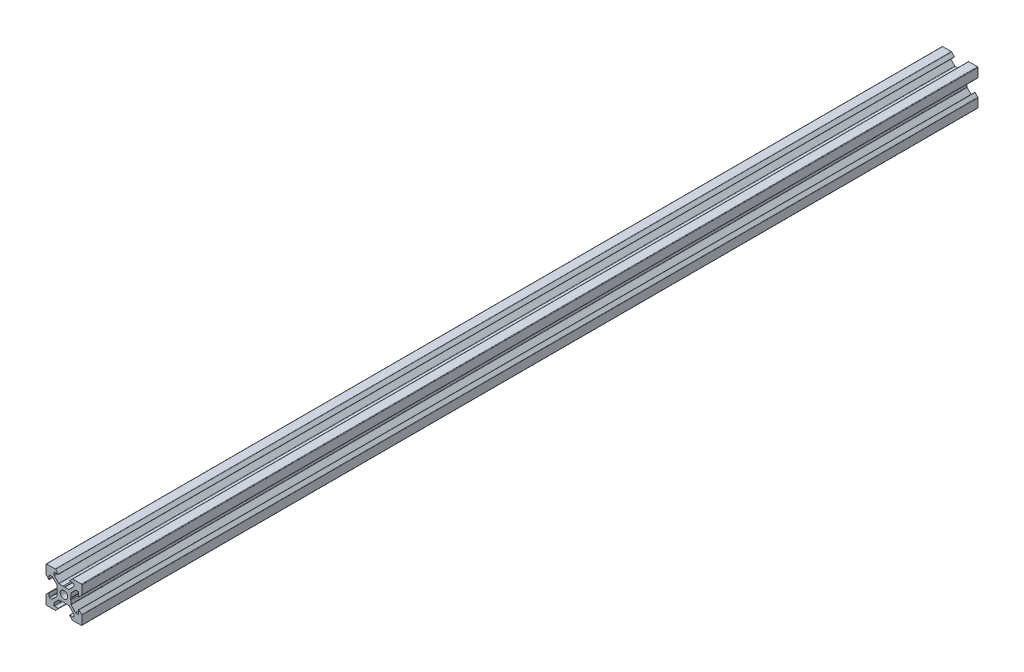
from build123d import *

# Parameters (mm, degrees)
BOSS_EXTRU_1_DEPTH = 500


with BuildPart() as part:
    # Esquisse1 → Boss.-Extru.1 (new body)
    with BuildSketch(Plane.XY):
        with BuildLine():
            Line((18.774857412, -2.895228684), (18.774857412, -4.894568513))
            ThreePointArc((18.774857412, -4.894568513), (18.686989447, -5.106700547), (18.474857412, -5.194568513))
            Line((18.474857412, -5.194568513), (17.259121481, -5.194568513))
            ThreePointArc((17.259121481, -5.194568513), (17.144316451, -5.171732372), (17.046989447, -5.106700547))
            Line((17.046989447, -5.106700547), (14.56338555, -2.62309665))
            ThreePointArc((14.56338555, -2.62309665), (14.498353724, -2.525769645), (14.475517584, -2.410964616))
            Line((14.475517584, -2.410964616), (14.475517584, -0.214843927))
            Line((14.475517584, -0.214843927), (14.175517584, 0.304771316))
            Line((14.175517584, 0.304771316), (14.475517584, 0.824386558))
            Line((14.475517584, 0.824386558), (14.475517584, 3.020507247))
            ThreePointArc((14.475517584, 3.020507247), (14.498353724, 3.135312277), (14.56338555, 3.232639281))
            Line((14.56338555, 3.232639281), (17.046989447, 5.716243178))
            ThreePointArc((17.046989447, 5.716243178), (17.144316451, 5.781275004), (17.259121481, 5.804111144))
            Line((17.259121481, 5.804111144), (18.474857412, 5.804111144))
            ThreePointArc((18.474857412, 5.804111144), (18.686989447, 5.716243178), (18.774857412, 5.504111144))
            Line((18.774857412, 5.504111144), (18.774857412, 3.504771316))
            ThreePointArc((18.774857412, 3.504771316), (18.836589069, 3.412383362), (18.94556809, 3.434060638))
            Line((18.94556809, 3.434060638), (20.486989447, 4.975481994))
            ThreePointArc((20.486989447, 4.975481994), (20.552021272, 5.072808998), (20.574857412, 5.187614028))
            Line((20.574857412, 5.187614028), (20.574857412, 10.004771316))
            ThreePointArc((20.574857412, 10.004771316), (20.486989447, 10.21690335), (20.274857412, 10.304771316))
            Line((20.274857412, 10.304771316), (15.457700125, 10.304771316))
            ThreePointArc((15.457700125, 10.304771316), (15.342895095, 10.281935175), (15.24556809, 10.21690335))
            Line((15.24556809, 10.21690335), (13.704146734, 8.675481994))
            ThreePointArc((13.704146734, 8.675481994), (13.682469459, 8.566502972), (13.774857412, 8.504771316))
            Line((13.774857412, 8.504771316), (15.77419724, 8.504771316))
            ThreePointArc((15.77419724, 8.504771316), (15.986329275, 8.41690335), (16.07419724, 8.204771316))
            Line((16.07419724, 8.204771316), (16.07419724, 6.989035384))
            ThreePointArc((16.07419724, 6.989035384), (16.0513611, 6.874230355), (15.986329275, 6.77690335))
            Line((15.986329275, 6.77690335), (13.502725378, 4.293299453))
            ThreePointArc((13.502725378, 4.293299453), (13.405398373, 4.228267628), (13.290593344, 4.205431487))
            Line((13.290593344, 4.205431487), (11.094472654, 4.205431487))
            Line((11.094472654, 4.205431487), (10.574857412, 3.905431487))
            Line((10.574857412, 3.905431487), (10.05524217, 4.205431487))
            Line((10.05524217, 4.205431487), (7.859121481, 4.205431487))
            ThreePointArc((7.859121481, 4.205431487), (7.744316451, 4.228267628), (7.646989447, 4.293299453))
            Line((7.646989447, 4.293299453), (5.16338555, 6.77690335))
            ThreePointArc((5.16338555, 6.77690335), (5.098353724, 6.874230355), (5.075517584, 6.989035384))
            Line((5.075517584, 6.989035384), (5.075517584, 8.204771316))
            ThreePointArc((5.075517584, 8.204771316), (5.16338555, 8.41690335), (5.375517584, 8.504771316))
            Line((5.375517584, 8.504771316), (7.374857412, 8.504771316))
            ThreePointArc((7.374857412, 8.504771316), (7.467245365, 8.566502972), (7.44556809, 8.675481994))
            Line((7.44556809, 8.675481994), (5.904146734, 10.21690335))
            ThreePointArc((5.904146734, 10.21690335), (5.806819729, 10.281935175), (5.6920147, 10.304771316))
            Line((5.6920147, 10.304771316), (0.874857412, 10.304771316))
            ThreePointArc((0.874857412, 10.304771316), (0.662725378, 10.21690335), (0.574857412, 10.004771316))
            Line((0.574857412, 10.004771316), (0.574857412, 5.187614028))
            ThreePointArc((0.574857412, 5.187614028), (0.597693552, 5.072808998), (0.662725378, 4.975481994))
            Line((0.662725378, 4.975481994), (2.204146734, 3.434060638))
            ThreePointArc((2.204146734, 3.434060638), (2.313125755, 3.412383362), (2.374857412, 3.504771316))
            Line((2.374857412, 3.504771316), (2.374857412, 5.504111144))
            ThreePointArc((2.374857412, 5.504111144), (2.462725378, 5.716243178), (2.674857412, 5.804111144))
            Line((2.674857412, 5.804111144), (3.890593344, 5.804111144))
            ThreePointArc((3.890593344, 5.804111144), (4.005398373, 5.781275004), (4.102725378, 5.716243178))
            Line((4.102725378, 5.716243178), (6.586329275, 3.232639281))
            ThreePointArc((6.586329275, 3.232639281), (6.6513611, 3.135312277), (6.67419724, 3.020507247))
            Line((6.67419724, 3.020507247), (6.67419724, 0.824386558))
            Line((6.67419724, 0.824386558), (6.97419724, 0.304771316))
            Line((6.97419724, 0.304771316), (6.67419724, -0.214843927))
            Line((6.67419724, -0.214843927), (6.67419724, -2.410964616))
            ThreePointArc((6.67419724, -2.410964616), (6.6513611, -2.525769645), (6.586329275, -2.62309665))
            Line((6.586329275, -2.62309665), (4.102725378, -5.106700547))
            ThreePointArc((4.102725378, -5.106700547), (4.005398373, -5.171732372), (3.890593344, -5.194568513))
            Line((3.890593344, -5.194568513), (2.674857412, -5.194568513))
            ThreePointArc((2.674857412, -5.194568513), (2.462725378, -5.106700547), (2.374857412, -4.894568513))
            Line((2.374857412, -4.894568513), (2.374857412, -2.895228684))
            ThreePointArc((2.374857412, -2.895228684), (2.313125755, -2.802840731), (2.204146734, -2.824518006))
            Line((2.204146734, -2.824518006), (0.662725378, -4.365939362))
            ThreePointArc((0.662725378, -4.365939362), (0.597693552, -4.463266367), (0.574857412, -4.578071397))
            Line((0.574857412, -4.578071397), (0.574857412, -9.395228684))
            ThreePointArc((0.574857412, -9.395228684), (0.662725378, -9.607360719), (0.874857412, -9.695228684))
            Line((0.874857412, -9.695228684), (5.6920147, -9.695228684))
            ThreePointArc((5.6920147, -9.695228684), (5.806819729, -9.672392544), (5.904146734, -9.607360719))
            Line((5.904146734, -9.607360719), (7.44556809, -8.065939362))
            ThreePointArc((7.44556809, -8.065939362), (7.467245365, -7.956960341), (7.374857412, -7.895228684))
            Line((7.374857412, -7.895228684), (5.375517584, -7.895228684))
            ThreePointArc((5.375517584, -7.895228684), (5.16338555, -7.807360719), (5.075517584, -7.595228684))
            Line((5.075517584, -7.595228684), (5.075517584, -6.379492753))
            ThreePointArc((5.075517584, -6.379492753), (5.098353724, -6.264687723), (5.16338555, -6.167360719))
            Line((5.16338555, -6.167360719), (7.646989447, -3.683756822))
            ThreePointArc((7.646989447, -3.683756822), (7.744316451, -3.618724996), (7.859121481, -3.595888856))
            Line((7.859121481, -3.595888856), (10.05524217, -3.595888856))
            Line((10.05524217, -3.595888856), (10.574857412, -3.295888856))
            Line((10.574857412, -3.295888856), (11.094472654, -3.595888856))
            Line((11.094472654, -3.595888856), (13.290593344, -3.595888856))
            ThreePointArc((13.290593344, -3.595888856), (13.405398373, -3.618724996), (13.502725378, -3.683756822))
            Line((13.502725378, -3.683756822), (15.986329275, -6.167360719))
            ThreePointArc((15.986329275, -6.167360719), (16.0513611, -6.264687723), (16.07419724, -6.379492753))
            Line((16.07419724, -6.379492753), (16.07419724, -7.595228684))
            ThreePointArc((16.07419724, -7.595228684), (15.986329275, -7.807360719), (15.77419724, -7.895228684))
            Line((15.77419724, -7.895228684), (13.774857412, -7.895228684))
            ThreePointArc((13.774857412, -7.895228684), (13.682469459, -7.956960341), (13.704146734, -8.065939362))
            Line((13.704146734, -8.065939362), (15.24556809, -9.607360719))
            ThreePointArc((15.24556809, -9.607360719), (15.342895095, -9.672392544), (15.457700125, -9.695228684))
            Line((15.457700125, -9.695228684), (20.274857412, -9.695228684))
            ThreePointArc((20.274857412, -9.695228684), (20.486989447, -9.607360719), (20.574857412, -9.395228684))
            Line((20.574857412, -9.395228684), (20.574857412, -4.578071397))
            ThreePointArc((20.574857412, -4.578071397), (20.552021272, -4.463266367), (20.486989447, -4.365939362))
            Line((20.486989447, -4.365939362), (18.94556809, -2.824518006))
            ThreePointArc((18.94556809, -2.824518006), (18.836589069, -2.802840731), (18.774857412, -2.895228684))
        make_face()
        with BuildLine():
            ThreePointArc((10.574857412, -1.795228684), (12.059781653, -1.180152925), (12.674857412, 0.304771316))
            ThreePointArc((12.674857412, 0.304771316), (12.059781653, 1.789695556), (10.574857412, 2.404771316))
            ThreePointArc((10.574857412, 2.404771316), (9.089933172, 1.789695556), (8.474857412, 0.304771316))
            ThreePointArc((8.474857412, 0.304771316), (9.089933172, -1.180152925), (10.574857412, -1.795228684))
        make_face(mode=Mode.SUBTRACT)
    extrude(amount=BOSS_EXTRU_1_DEPTH)


solid = part.part
